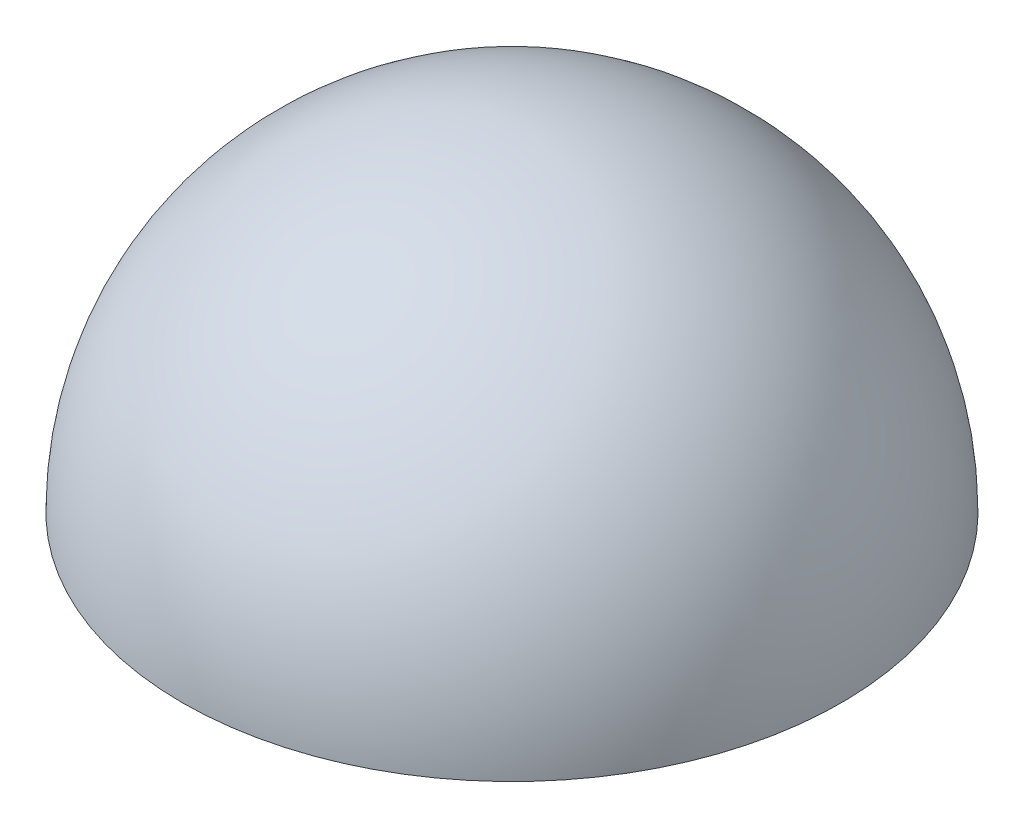
from build123d import *


with BuildPart() as part:
    # Sketch2 → Revolve2 (revolve)
    with BuildSketch(Plane(origin=(0, 0, 0), x_dir=(0, 0, -1), z_dir=(1, 0, 0))):
        with BuildLine():
            Line((0, 20), (0, 0))
            Line((0, 0), (-20, 0))
            ThreePointArc((-20, 0), (-14.142135624, 14.142135624), (0, 20))
        make_face()
    revolve(axis=Axis((0, 1.617, 0), (0, -1, 0)))

    # Sketch3 → Cut-Revolve1 (revolve, cut)
    with BuildSketch(Plane(origin=(0, 0, 0), x_dir=(0, 0, -1), z_dir=(1, 0, 0))):
        with BuildLine():
            Line((0, 19.6), (0, 0))
            Line((0, 0), (-19.6, 0))
            ThreePointArc((-19.6, 0), (-13.859292911, 13.859292911), (0, 19.6))
        make_face()
    revolve(axis=Axis((0, 19.6, 0), (0, -1, 0)), mode=Mode.SUBTRACT)


solid = part.part
